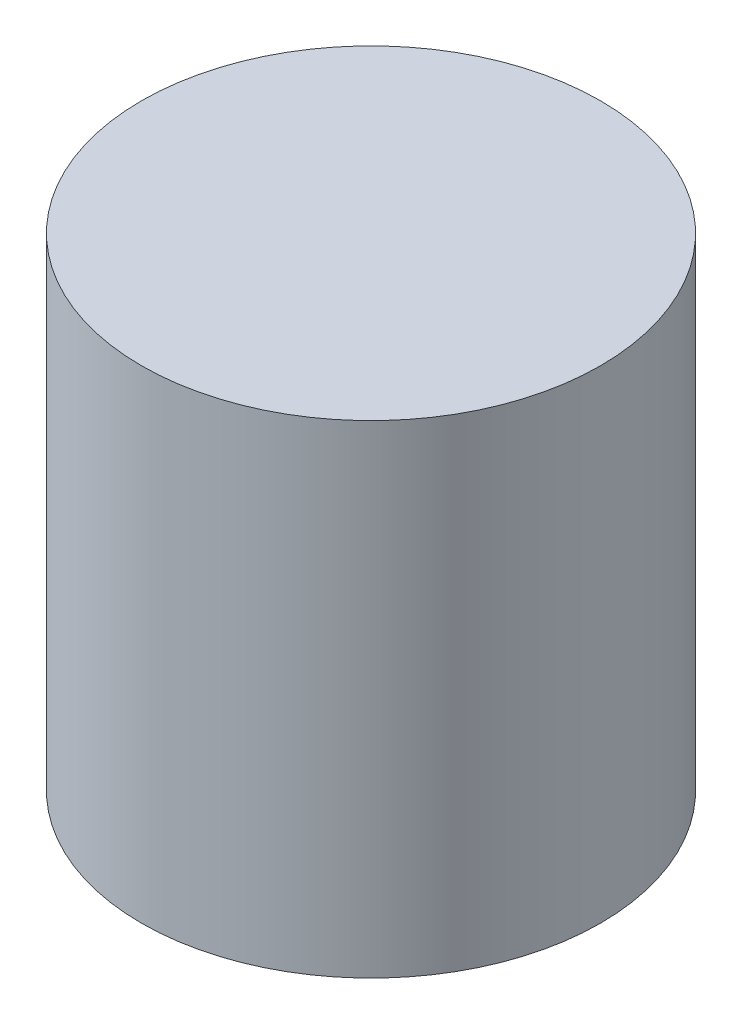
from build123d import *

# Parameters (mm, degrees)
SKETCH1_R      = 67.5
EXTRUDE1_DEPTH = 142


with BuildPart() as part:
    # Sketch1 → Extrude1 (new body)
    with BuildSketch(Plane(origin=(0, 0, 0), x_dir=(1, 0, 0), z_dir=(0, 1, 0))):
        with Locations(Location((0, 0, 0), (0, 0, 270))):  # turned: the seam where the file's is
            Circle(SKETCH1_R)
    extrude(amount=EXTRUDE1_DEPTH)


solid = part.part
